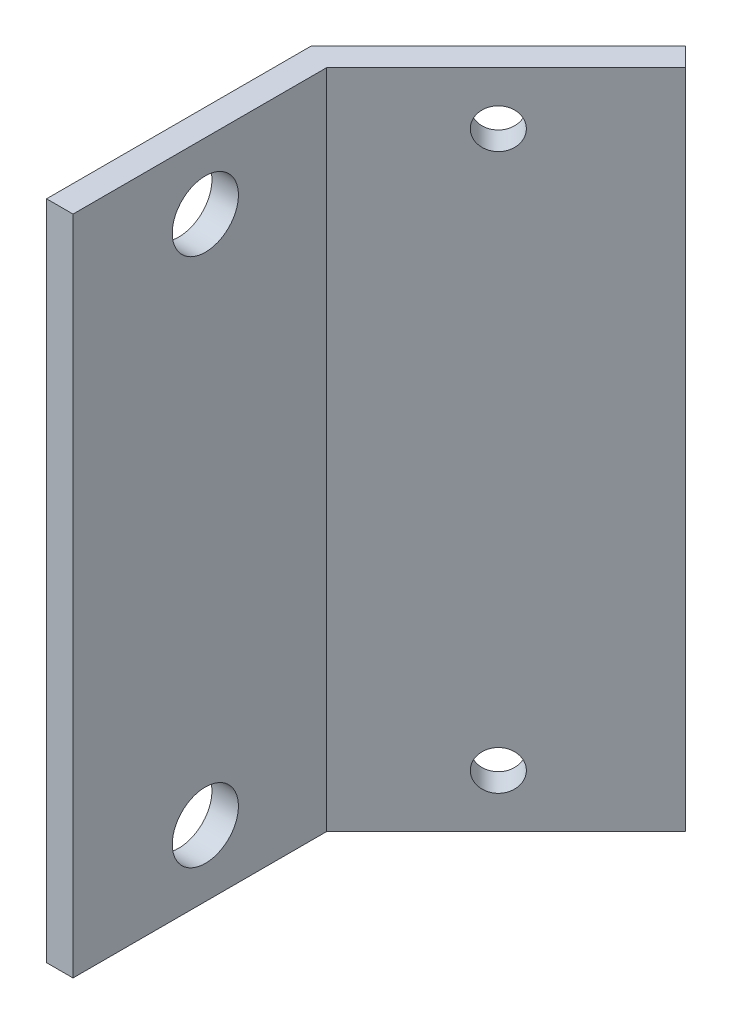
from build123d import *

# Parameters (mm, degrees)
EXTRUSION1_DEPTH = 50
EXTRUSION2_REACH = 17.556
ESQUISSE3_R      = 2.5
EXTRUSION3_REACH = 27.142
ESQUISSE4_R      = 1.5


with BuildPart() as part:
    # Esquisse1 → Extrusion1 (new body)
    with BuildSketch(Plane(origin=(0, 0, 0), x_dir=(1, 0, 0), z_dir=(0, 1, 0))):
        Polygon((0, 0), (0, 20), (14.142135624, 34.142135624), (15.556349186, 32.727922061), (2, 19.171572875), (2, 0), align=None)
    extrude(amount=EXTRUSION1_DEPTH)

    # Esquisse3 → Extrusion2 (cut, up to next)
    with BuildSketch(Plane.ZY, mode=Mode.PRIVATE) as extrusion2_sk1:
        with Locations((-10, 5)):
            Circle(ESQUISSE3_R)
    extrusion2_tool1 = extrude(extrusion2_sk1.sketch, amount=-EXTRUSION2_REACH, mode=Mode.PRIVATE) & part.part
    add(extrusion2_tool1.solids().sort_by_distance((0, 5, -10))[0], mode=Mode.SUBTRACT)
    # Esquisse3 → Extrusion2 (cut, up to next)
    with BuildSketch(Plane.ZY, mode=Mode.PRIVATE) as extrusion2_sk2:
        with Locations((-10, 45)):
            Circle(ESQUISSE3_R)
    extrusion2_tool2 = extrude(extrusion2_sk2.sketch, amount=-EXTRUSION2_REACH, mode=Mode.PRIVATE) & part.part
    add(extrusion2_tool2.solids().sort_by_distance((0, 45, -10))[0], mode=Mode.SUBTRACT)

    # Esquisse4 → Extrusion3 (cut, up to next)
    with BuildSketch(Plane(origin=(-10, 0, -10), x_dir=(-0.707106781, 0, 0.707106781), z_dir=(-0.707106781, 0, -0.707106781)), mode=Mode.PRIVATE) as extrusion3_sk1:
        with Locations((-24.142135624, 46)):
            Circle(ESQUISSE4_R)
    extrusion3_tool1 = extrude(extrusion3_sk1.sketch, amount=-EXTRUSION3_REACH, mode=Mode.PRIVATE) & part.part
    add(extrusion3_tool1.solids().sort_by_distance((7.071068, 46, -27.071068))[0], mode=Mode.SUBTRACT)
    # Esquisse4 → Extrusion3 (cut, up to next)
    with BuildSketch(Plane(origin=(-10, 0, -10), x_dir=(-0.707106781, 0, 0.707106781), z_dir=(-0.707106781, 0, -0.707106781)), mode=Mode.PRIVATE) as extrusion3_sk2:
        with Locations((-24.142135624, 4)):
            Circle(ESQUISSE4_R)
    extrusion3_tool2 = extrude(extrusion3_sk2.sketch, amount=-EXTRUSION3_REACH, mode=Mode.PRIVATE) & part.part
    add(extrusion3_tool2.solids().sort_by_distance((7.071068, 4, -27.071068))[0], mode=Mode.SUBTRACT)


solid = part.part
